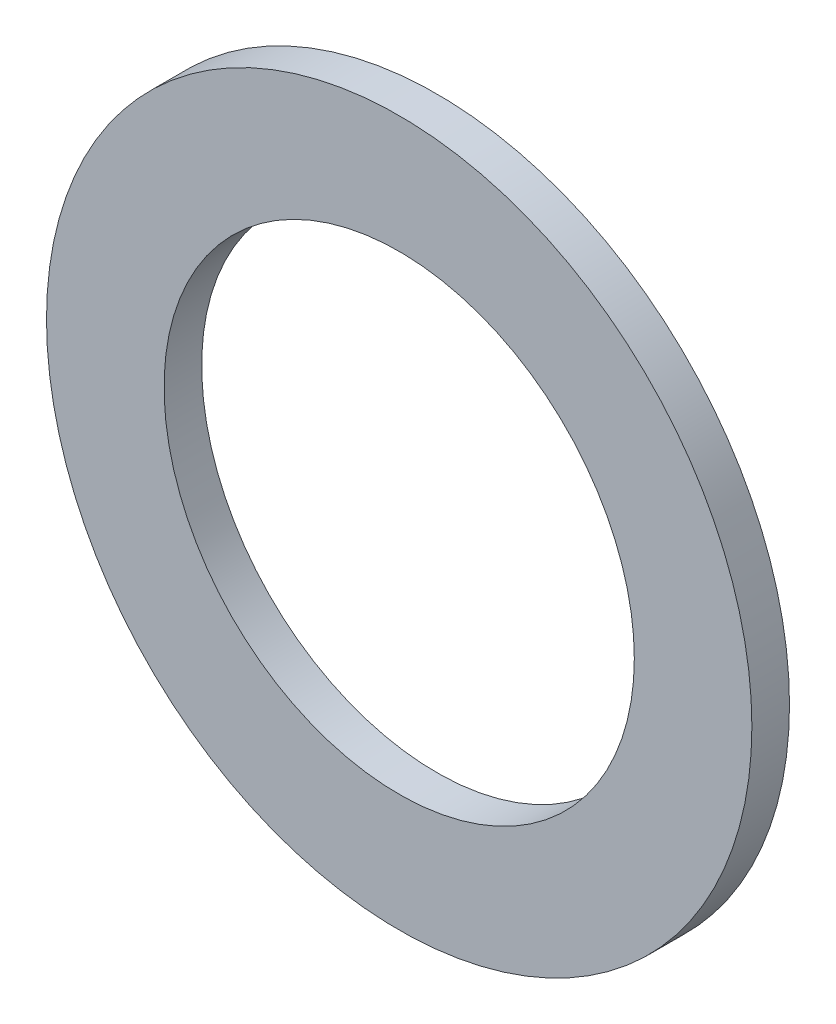
from build123d import *

# Parameters (mm, degrees)
SKETCH3_R           = 2.38125
SKETCH3_R_2         = 1.5875
BOSS_EXTRUDE1_DEPTH = 0.127


with BuildPart() as part:
    # Sketch3 → Boss-Extrude1 (new, symmetric)
    with BuildSketch(Plane.XY):
        Circle(SKETCH3_R)
        Circle(SKETCH3_R_2, mode=Mode.SUBTRACT)
    extrude(amount=BOSS_EXTRUDE1_DEPTH, both=True)


solid = part.part
